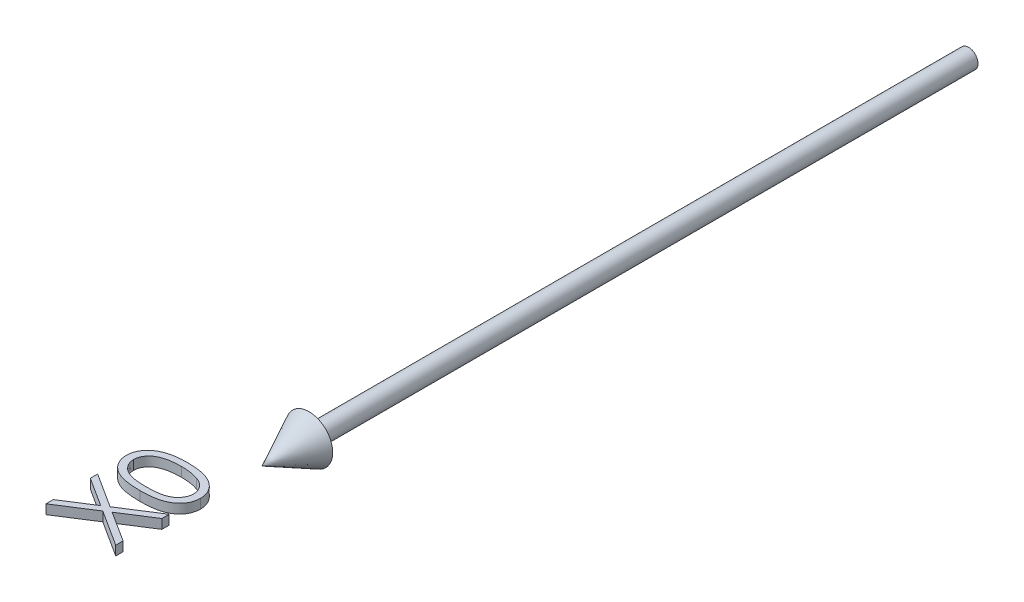
from build123d import *

# Parameters (mm, degrees)
BOSS_EXTRUDE1_DEPTH        = 1
BOSS_EXTRUDE1_DEPTH_BACK   = 1
BOSS_EXTRUDE1_2_DEPTH      = 1
BOSS_EXTRUDE1_2_DEPTH_BACK = 1


with BuildPart() as part:
    # Sketch2 → Revolve1 (revolve)
    with BuildSketch(Plane(origin=(0, 0, 0), x_dir=(1, 0, 0), z_dir=(0, 1, 0))):
        Polygon((0, -150), (5, -140), (2, -140), (2, 0), (0, 0), align=None)
    revolve(axis=Axis((0, 0, -41.949952025), (0, 0, 1)))


with BuildPart() as body_2:
    # Sketch3 → Boss-Extrude1 (new, two sides: drawn at the far end of the back side and taken through both)
    with BuildSketch(Plane(origin=(0, 0, 0), x_dir=(1, 0, 0), z_dir=(0, 1, 0)).offset(-BOSS_EXTRUDE1_DEPTH_BACK)):
        with BuildLine():
            add(Edge.make_bspline(
                [(-7.493990385, -168.461538462), (-7.734407761, -168.460132669), (-8.201421979, -168.457401898), (-8.881927587, -168.427022951), (-9.520328827, -168.376557199), (-10.11665625, -168.307397027), (-10.671063822, -168.223234264), (-11.182069889, -168.110882146), (-11.652039749, -167.983113101), (-12.082505278, -167.835030824), (-12.479268217, -167.667941561), (-12.849657159, -167.486075994), (-13.193139524, -167.282242653), (-13.515098063, -167.067999479), (-13.810615561, -166.83500601), (-14.08309694, -166.58825807), (-14.330244312, -166.322820666), (-14.552226925, -166.041268298), (-14.746873286, -165.745509178), (-14.919380346, -165.443625294), (-15.061473493, -165.130222656), (-15.177709598, -164.80942703), (-15.272595813, -164.480562303), (-15.337772922, -164.14371243), (-15.378709332, -163.798096568), (-15.382628022, -163.564820357), (-15.384615385, -163.446514423)],
                knots=[0, 0, 0, 0, 1.646148282, 3.197666765, 4.66315463, 6.030252048, 7.307778049, 8.501004361, 9.610818041, 10.641065266, 11.615491391, 12.557119604, 13.464013759, 14.348536654, 15.203310953, 16.038349431, 16.863300206, 17.683791446, 18.490318933, 19.285717724, 20.06220424, 20.843281102, 21.620494212, 22.403315558, 23.190242141, 24, 24, 24, 24], degree=3))
            add(Edge.make_bspline(
                [(-15.384615385, -163.446514423), (-15.382960028, -163.327161661), (-15.379666451, -163.089691672), (-15.33330737, -162.739869608), (-15.273470363, -162.396140848), (-15.177501658, -162.063720436), (-15.062662656, -161.736322939), (-14.911134418, -161.42209008), (-14.746335691, -161.109927773), (-14.545295108, -160.814017136), (-14.323112179, -160.5255169), (-14.070877754, -160.25507805), (-13.795572446, -159.995787447), (-13.491056145, -159.757438395), (-13.161997985, -159.529815585), (-12.805639513, -159.321559808), (-12.422770469, -159.128339726), (-12.015165777, -158.946523312), (-11.571937683, -158.787529659), (-11.095850718, -158.646171592), (-10.582593685, -158.530304738), (-10.035025751, -158.434484886), (-9.450434272, -158.360110442), (-8.830003698, -158.305981978), (-8.173345879, -158.27737979), (-7.724383527, -158.271994387), (-7.493990385, -158.269230769)],
                knots=[0, 0, 0, 0, 0.810910589, 1.61342667, 2.396193133, 3.181089899, 3.963115317, 4.752255436, 5.550715454, 6.36105385, 7.181178335, 8.024612154, 8.872680183, 9.750181803, 10.651284446, 11.591556747, 12.554036451, 13.566402641, 14.62422919, 15.753422176, 16.94128843, 18.199818041, 19.531985927, 20.947085226, 22.433341622, 24, 24, 24, 24], degree=3))
            add(Edge.make_bspline(
                [(-7.493990385, -158.269230769), (-7.264604216, -158.272055188), (-6.816654145, -158.27757077), (-6.162920169, -158.305368541), (-5.545833851, -158.36143255), (-4.964737284, -158.430538497), (-4.419361049, -158.527429317), (-3.910060515, -158.644174744), (-3.435032524, -158.777188795), (-2.99768059, -158.938622573), (-2.590783215, -159.116207063), (-2.210729382, -159.309219805), (-1.854465021, -159.516300361), (-1.524538919, -159.740509357), (-1.221244895, -159.982779009), (-0.944995341, -160.241887872), (-0.691156597, -160.51468797), (-0.466525872, -160.804870112), (-0.263954666, -161.103536976), (-0.093175488, -161.415730996), (0.054794652, -161.733462289), (0.175773888, -162.059903098), (0.2695947, -162.394549418), (0.334091398, -162.738513772), (0.379427623, -163.089741039), (0.382880143, -163.327178174), (0.384615385, -163.446514423)],
                knots=[0, 0, 0, 0, 1.561645053, 3.049612875, 4.452756685, 5.778837748, 7.032101753, 8.221335837, 9.334924186, 10.387562255, 11.392109817, 12.355697819, 13.287721948, 14.19548756, 15.068665045, 15.927346723, 16.771751757, 17.602390507, 18.423119567, 19.225778204, 20.022010933, 20.807278863, 21.593079439, 22.384715467, 23.188155646, 24, 24, 24, 24], degree=3))
            add(Edge.make_bspline(
                [(0.384615385, -163.446514423), (0.382616718, -163.564817769), (0.378675738, -163.798088875), (0.337902604, -164.143742128), (0.272350445, -164.47923831), (0.180565008, -164.806232984), (0.068215675, -165.126403712), (-0.078157124, -165.43538799), (-0.246732198, -165.73662019), (-0.438710698, -166.029301069), (-0.658667943, -166.307913992), (-0.901916131, -166.574091346), (-1.174692968, -166.820900134), (-1.472703873, -167.05187334), (-1.795141429, -167.26838145), (-2.142222022, -167.470453401), (-2.514538298, -167.656132828), (-2.91443689, -167.826076781), (-3.347957668, -167.976751057), (-3.819125522, -168.109329708), (-4.332726118, -168.215216206), (-4.886151799, -168.30497138), (-5.480527086, -168.376893378), (-6.116067016, -168.427001995), (-6.791564752, -168.457378835), (-7.255575818, -168.460126617), (-7.493990385, -168.461538462)],
                knots=[0, 0, 0, 0, 0.810927267, 1.598990287, 2.382942141, 3.152806972, 3.926217614, 4.706701772, 5.493896336, 6.292070767, 7.104102563, 7.925577746, 8.761822141, 9.623241997, 10.509042271, 11.423174113, 12.375371989, 13.360203808, 14.400680605, 15.520553799, 16.714061498, 17.994519714, 19.364400916, 20.818312473, 22.365209998, 24, 24, 24, 24], degree=3))
        make_face()
        with BuildLine():
            add(Edge.make_bspline(
                [(-7.5, -167.115384615), (-7.299649235, -167.114861474), (-6.91080774, -167.11384616), (-6.346752781, -167.088089414), (-5.819774782, -167.052238649), (-5.330079419, -167.007136324), (-4.879378162, -166.939589179), (-4.465797283, -166.862952813), (-4.090102312, -166.77103217), (-3.74901012, -166.661737271), (-3.437690705, -166.537239745), (-3.147846302, -166.401548987), (-2.876041714, -166.254486827), (-2.622936378, -166.093038813), (-2.391624229, -165.914013002), (-2.176242033, -165.725709053), (-1.984280592, -165.519643977), (-1.754014466, -165.23464061), (-1.516079182, -164.858364023), (-1.308880488, -164.384278164), (-1.178670253, -163.897127207), (-1.16211126, -163.566479052), (-1.153846154, -163.401442308)],
                knots=[0, 0, 0, 0, 1.459098681, 2.831824031, 4.11146945, 5.306290378, 6.412266529, 7.42953815, 8.369053297, 9.227277979, 10.03601793, 10.809473603, 11.557037441, 12.285528272, 12.993193355, 13.685654407, 14.36688038, 15.041354379, 16.352855396, 17.594313975, 18.799247529, 20, 20, 20, 20], degree=3))
            add(Edge.make_bspline(
                [(-1.153846154, -163.401442308), (-1.161083242, -163.23545023), (-1.175531747, -162.904054882), (-1.301632605, -162.417351422), (-1.506632555, -161.94876648), (-1.740840139, -161.578964212), (-1.96531168, -161.29840593), (-2.156474594, -161.097316381), (-2.370583043, -160.912769396), (-2.601576726, -160.73773064), (-2.85388829, -160.577192104), (-3.126299066, -160.431207126), (-3.419567044, -160.297992807), (-3.624294488, -160.222096892), (-3.728966346, -160.183293269)],
                knots=[0, 0, 0, 0, 1.353621445, 2.702441307, 4.075953605, 5.516772412, 6.261413105, 7.007624062, 7.778524365, 8.566925914, 9.372323995, 10.217594641, 11.088702136, 12, 12, 12, 12], degree=3))
            add(Edge.make_bspline(
                [(-3.728966346, -160.183293269), (-3.862808087, -160.138071407), (-4.134564219, -160.046251634), (-4.556122728, -159.927915458), (-4.998420288, -159.83472089), (-5.458813645, -159.750877894), (-5.940698078, -159.693650512), (-6.442582581, -159.647588455), (-6.964845562, -159.620456939), (-7.319681238, -159.61709372), (-7.5, -159.615384615)],
                knots=[0, 0, 0, 0, 0.884706709, 1.796334032, 2.740027952, 3.714592787, 4.726048262, 5.777819803, 6.87074269, 8, 8, 8, 8], degree=3))
            add(Edge.make_bspline(
                [(-7.5, -159.615384615), (-7.680289597, -159.617742569), (-8.032974588, -159.622355231), (-8.549481077, -159.639986607), (-9.040057196, -159.685516211), (-9.506816361, -159.736083866), (-9.947174812, -159.810643375), (-10.364818942, -159.89103401), (-10.754574884, -159.999039088), (-11.122544099, -160.114409962), (-11.464548365, -160.246453094), (-11.782173829, -160.391811147), (-12.076983164, -160.547030097), (-12.348065488, -160.71569967), (-12.596993203, -160.895470467), (-12.818038495, -161.092788059), (-13.021954001, -161.295121317), (-13.250558341, -161.58288186), (-13.485487036, -161.956547681), (-13.695801559, -162.4247215), (-13.820271369, -162.90926122), (-13.837532574, -163.237500238), (-13.846153846, -163.401442308)],
                knots=[0, 0, 0, 0, 1.313483664, 2.569454835, 3.763100662, 4.901599063, 5.988328865, 7.015709358, 7.99797933, 8.932480776, 9.824041341, 10.666387587, 11.475829342, 12.24921787, 12.990555181, 13.709176526, 14.405678811, 15.080244297, 16.38186033, 17.610124501, 18.806354173, 20, 20, 20, 20], degree=3))
            add(Edge.make_bspline(
                [(-13.846153846, -163.401442308), (-13.837511125, -163.567370047), (-13.820209939, -163.899527806), (-13.696377194, -164.389241957), (-13.486102376, -164.860578573), (-13.251010958, -165.235476607), (-13.022830494, -165.519741343), (-12.828622647, -165.721462266), (-12.618384757, -165.912377734), (-12.385020606, -166.086767692), (-12.132807088, -166.247258367), (-11.864517407, -166.400003953), (-11.574131433, -166.533880168), (-11.263056133, -166.658777387), (-10.92194518, -166.768254588), (-10.544890815, -166.859124936), (-10.130322276, -166.941851642), (-9.676327937, -167.001428355), (-9.186528059, -167.053889607), (-8.658202405, -167.087695837), (-8.092210531, -167.113964153), (-7.701357234, -167.114901644), (-7.5, -167.115384615)],
                knots=[0, 0, 0, 0, 1.207546505, 2.417292871, 3.651582144, 4.952510111, 5.626719005, 6.30238548, 6.989136872, 7.692112372, 8.420316868, 9.164734959, 9.937886623, 10.746308695, 11.604196049, 12.543341915, 13.568754172, 14.680483261, 15.875568977, 17.154711427, 18.534182925, 20, 20, 20, 20], degree=3))
        make_face(mode=Mode.SUBTRACT)
    extrude(amount=BOSS_EXTRUDE1_DEPTH + BOSS_EXTRUDE1_DEPTH_BACK)


with BuildPart() as body_3:
    # Sketch3 → Boss-Extrude1 2 (new, two sides: drawn at the far end of the back side and taken through both)
    with BuildSketch(Plane(origin=(0, 0, 0), x_dir=(1, 0, 0), z_dir=(0, 1, 0)).offset(-BOSS_EXTRUDE1_2_DEPTH_BACK)):
        Polygon((-15, -180.865384615), (-15, -179.311899038), (-8.864182692, -175.384615385), (-15, -171.457331731), (-15, -169.903846154), (-7.650240385, -174.606370192), (0, -169.711538462), (0, -171.265024038), (-6.436298077, -175.384615385), (0, -179.504206731), (0, -181.057692308), (-7.650240385, -176.159855769), align=None)
    extrude(amount=BOSS_EXTRUDE1_2_DEPTH + BOSS_EXTRUDE1_2_DEPTH_BACK)


solid = Compound([part.part, body_2.part, body_3.part])
